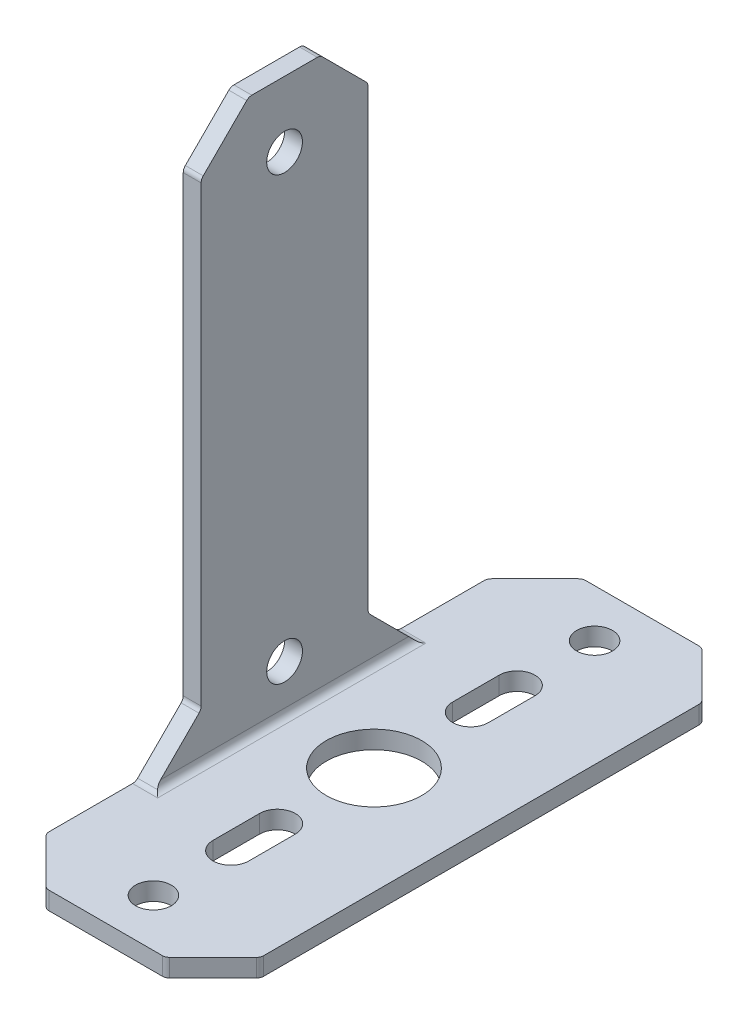
from build123d import *

# Parameters (mm, degrees)
EXTRUDE_1_DEPTH     = 22.5
SKETCH_2_R          = 4
SKETCH_2_R_2        = 1.5
CUT_EXTRUDE_1_DEPTH = 45.2
CHAMFER_1_SIZE      = 4
SKETCH_4_R          = 1.5
CUT_EXTRUDE_2_DEPTH = 56.98437282
CUT_EXTRUDE_3_DEPTH = 10
CHAMFER_2_SIZE      = 4
CHAMFER_4_SIZE      = 4
FILLET_2_R          = 0.6
CHAMFER_5_SIZE      = 4
FILLET_3_R          = 0.6


with BuildPart() as part:
    # Эскиз1 → Бобышка-Вытянуть1 (new, symmetric)
    with BuildSketch(Plane.XY):
        Polygon((0, 0), (0, 48), (1.5, 48), (1.5, 1.5), (18, 1.5), (18, 0), align=None)
    extrude(amount=EXTRUDE_1_DEPTH, both=True)

    # Эскиз2 → Вырез-Вытянуть1 (cut)
    with BuildSketch(Plane(origin=(0, 1.5, 0), x_dir=(1, 0, 0), z_dir=(0, 1, 0))):
        with Locations((9, 0)):
            Circle(SKETCH_2_R)
        with Locations((9, 18.5)):
            Circle(SKETCH_2_R_2)
        with Locations((9, -18.5)):
            Circle(SKETCH_2_R_2)
        with BuildLine():
            Line((7.5, 8.1), (7.5, 12))
            ThreePointArc((7.5, 12), (9, 13.5), (10.5, 12))
            Line((10.5, 12), (10.5, 8.1))
            ThreePointArc((10.5, 8.1), (9, 6.6), (7.5, 8.1))
        make_face()
        with BuildLine():
            Line((10.5, -12), (10.5, -8.1))
            ThreePointArc((10.5, -8.1), (9, -6.6), (7.5, -8.1))
            Line((7.5, -8.1), (7.5, -12))
            ThreePointArc((7.5, -12), (9, -13.5), (10.5, -12))
        make_face()
    extrude(amount=-CUT_EXTRUDE_1_DEPTH, mode=Mode.SUBTRACT)

    # Фаска1
    chamfer_1_edges = [part.edges().sort_by_distance(p)[0] for p in [
        (18, 0.75, -22.5),
        (18, 0.75, 22.5),
        (0.75, 48, 22.5),
        (0.75, 48, -22.5),
    ]]
    chamfer(chamfer_1_edges, length=CHAMFER_1_SIZE)

    # Эскиз4 → Вырез-Вытянуть2 (cut, through all)
    with BuildSketch(Plane.ZY):
        with Locations((0, 42.5)):
            Circle(SKETCH_4_R)
        with Locations((0, 5.5)):
            Circle(SKETCH_4_R)
    extrude(amount=-CUT_EXTRUDE_2_DEPTH, mode=Mode.SUBTRACT)

    # Эскиз6 → Вырез-Вытянуть3 (cut)
    with BuildSketch(Plane.ZY):
        Polygon((7, 48), (7, 1.5), (33.1795091, 1.5), (33.1795091, 42.5), (33.38840833, 42.5), (33.38840833, 72.5), (7, 72.5), align=None)
        Polygon((-7, 72.5), (-33.38840833, 72.5), (-33.38840833, 42.5), (-22.5, 42.5), (-22.5, 1.5), (-7, 1.5), align=None)
    extrude(amount=-CUT_EXTRUDE_3_DEPTH, mode=Mode.SUBTRACT)

    # Фаска2
    chamfer_2_edges = [part.edges().sort_by_distance(p)[0] for p in [
        (0.75, 48, 7),
        (0.75, 48, -7),
    ]]
    chamfer(chamfer_2_edges, length=CHAMFER_2_SIZE)

    # Фаска4
    chamfer_4_edges = [part.edges().sort_by_distance(p)[0] for p in [
        (0.75, 1.5, 7),
        (0.75, 1.5, -7),
    ]]
    chamfer(chamfer_4_edges, length=CHAMFER_4_SIZE)

    # Скругление2
    fillet_2_edges = [part.edges().sort_by_distance(p)[0] for p in [
        (14, 0.75, 22.5),
        (18, 0.75, 18.5),
        (18, 0.75, -18.5),
        (14, 0.75, -22.5),
        (0.75, 5.5, -7),
        (0.75, 44, -7),
        (0.75, 48, -3),
        (0.75, 48, 3),
        (0.75, 44, 7),
        (0.75, 5.5, 7),
        (0.75, 1.5, 11),
        (0.75, 1.5, -11),
        (1.5, 1.5, 0),
    ]]
    fillet(fillet_2_edges, radius=FILLET_2_R)

    # Фаска5
    chamfer_5_edges = [part.edges().sort_by_distance(p)[0] for p in [
        (0, 0.75, 22.5),
        (0, 0.75, -22.5),
    ]]
    chamfer(chamfer_5_edges, length=CHAMFER_5_SIZE)

    # Скругление3
    fillet_3_edges = [part.edges().sort_by_distance(p)[0] for p in [
        (4, 0.75, 22.5),
        (0, 0.75, 18.5),
        (4, 0.75, -22.5),
        (0, 0.75, -18.5),
    ]]
    fillet(fillet_3_edges, radius=FILLET_3_R)


solid = part.part
